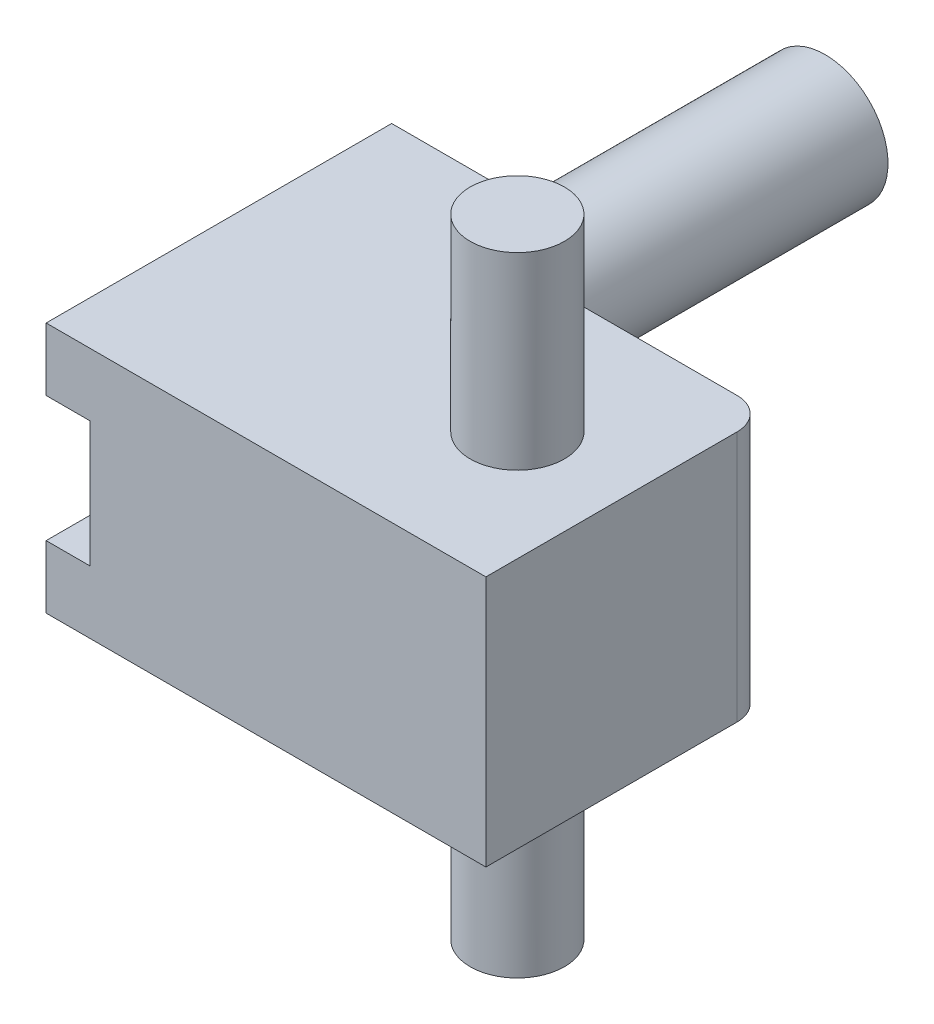
from build123d import *

# Parameters (mm, degrees)
CROQUIS2_W              = 70
CROQUIS2_H              = 40
SALIENTE_EXTRUIR1_DEPTH = 45
CROQUIS3_W              = 40.5
CROQUIS3_H              = 20
CORTAR_EXTRUIR1_DEPTH   = 39
CROQUIS4_W              = 7
CROQUIS4_H              = 20
CORTAR_EXTRUIR2_DEPTH   = 12
CROQUIS5_W              = 20
CROQUIS5_H              = 20
CORTAR_EXTRUIR4_DEPTH   = 7
CROQUIS6_R              = 7.5
SALIENTE_EXTRUIR3_DEPTH = 30
CROQUIS8_R              = 7.5
SALIENTE_EXTRUIR4_DEPTH = 30
CROQUIS9_W              = 30
CROQUIS9_H              = 40
SALIENTE_EXTRUIR5_DEPTH = 10
CROQUIS10_R             = 10
SALIENTE_EXTRUIR6_DEPTH = 54
REDONDEO1_R             = 5


with BuildPart() as part:
    # Croquis2 → Saliente-Extruir1 (new body)
    with BuildSketch(Plane.XY):
        with Locations((35, 20)):
            Rectangle(CROQUIS2_W, CROQUIS2_H)
    extrude(amount=SALIENTE_EXTRUIR1_DEPTH)

    # Croquis3 → Cortar-Extruir1 (cut)
    with BuildSketch(Plane(origin=(0, 0, 0), x_dir=(-1, 0, 0), z_dir=(0, 0, -1))):
        with Locations((-27.25, 20)):
            Rectangle(CROQUIS3_W, CROQUIS3_H)
    extrude(amount=-CORTAR_EXTRUIR1_DEPTH, mode=Mode.SUBTRACT)

    # Croquis4 → Cortar-Extruir2 (cut)
    with BuildSketch(Plane(origin=(0, 0, 0), x_dir=(-1, 0, 0), z_dir=(0, 0, -1))):
        with Locations((-3.5, 20)):
            Rectangle(CROQUIS4_W, CROQUIS4_H)
        with Locations((-51, 20)):
            Rectangle(CROQUIS4_W, CROQUIS4_H)
    extrude(amount=-CORTAR_EXTRUIR2_DEPTH, mode=Mode.SUBTRACT)

    # Croquis5 → Cortar-Extruir4 (cut)
    with BuildSketch(Plane.ZY):
        with Locations((35, 20)):
            Rectangle(CROQUIS5_W, CROQUIS5_H)
    extrude(amount=-CORTAR_EXTRUIR4_DEPTH, mode=Mode.SUBTRACT)

    # Croquis6 → Saliente-Extruir3 (add)
    with BuildSketch(Plane(origin=(0, 40, 0), x_dir=(1, 0, 0), z_dir=(0, 1, 0))):
        with Locations((52.5, -22.5)):
            Circle(CROQUIS6_R)
    extrude(amount=SALIENTE_EXTRUIR3_DEPTH)

    # Croquis8 → Saliente-Extruir4 (add)
    with BuildSketch(Plane.XZ):
        with Locations((52.5, 22.5)):
            Circle(CROQUIS8_R)
    extrude(amount=SALIENTE_EXTRUIR4_DEPTH)

    # Croquis9 → Saliente-Extruir5 (add)
    with BuildSketch(Plane(origin=(0, 0, 0), x_dir=(-1, 0, 0), z_dir=(0, 0, -1))):
        with Locations((-15, 20)):
            Rectangle(CROQUIS9_W, CROQUIS9_H)
    extrude(amount=SALIENTE_EXTRUIR5_DEPTH)

    # Croquis10 → Saliente-Extruir6 (add)
    with BuildSketch(Plane(origin=(0, 0, -10), x_dir=(-1, 0, 0), z_dir=(0, 0, -1))):
        with Locations((-15, 20)):
            Circle(CROQUIS10_R)
    extrude(amount=SALIENTE_EXTRUIR6_DEPTH)

    # Redondeo1
    redondeo1_edges = [part.edges().sort_by_distance(p)[0] for p in [
        (70, 20, 0),
    ]]
    fillet(redondeo1_edges, radius=REDONDEO1_R)


solid = part.part
